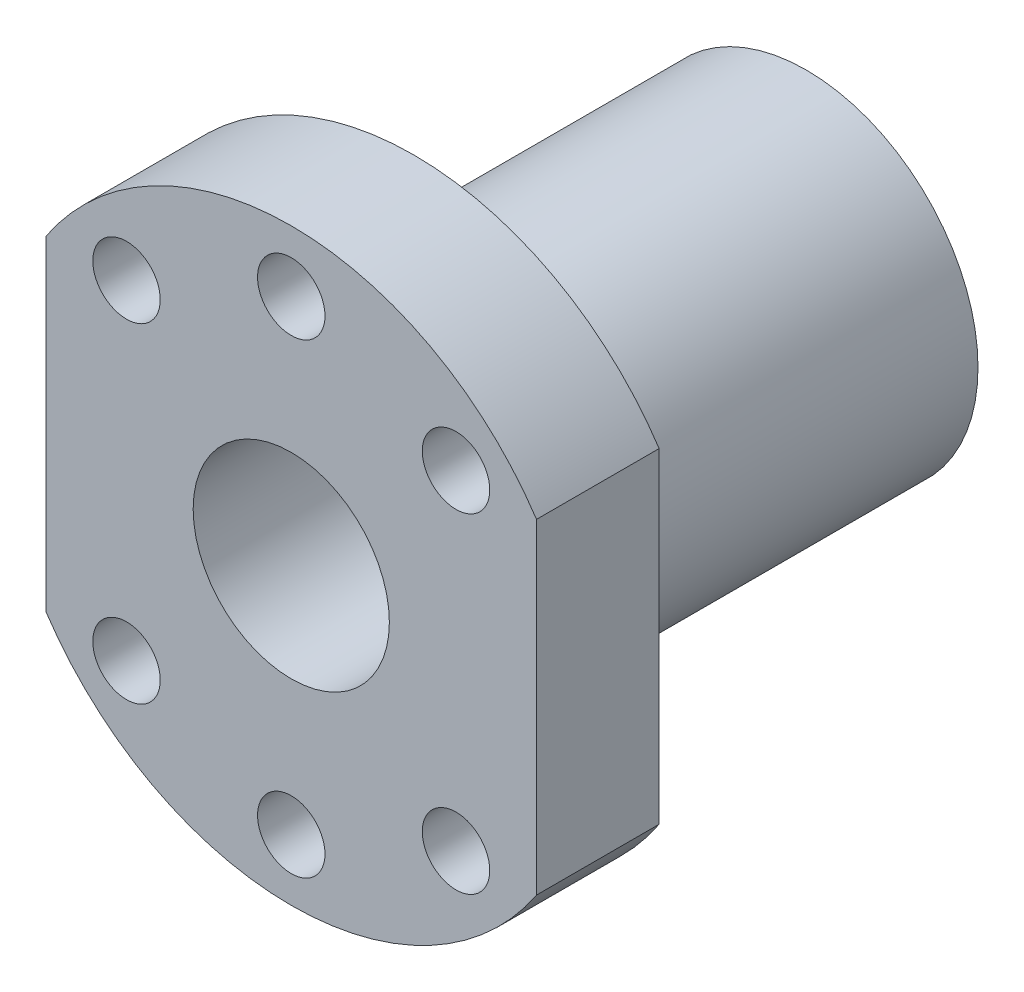
from build123d import *

# Parameters (mm, degrees)
EXTRUDE1_DEPTH = 10
SKETCH3_R      = 2.75
EXTRUDE2_DEPTH = 10


with BuildPart() as part:
    # Sketch1 → Revolve1 (revolve)
    with BuildSketch(Plane(origin=(0, 0, 0), x_dir=(0, 0, -1), z_dir=(1, 0, 0))):
        Polygon((-27.228213729, 44.343190328), (-17.228213729, 44.343190328), (-17.228213729, 34.343190328), (14.771786271, 34.343190328), (14.771786271, 28.343190328), (-27.228213729, 28.343190328), align=None)
    revolve(axis=Axis((0, 20.343190328, 76.875109204), (0, 0, -1)))

    # Sketch2 → Extrude1 (cut)
    with BuildSketch(Plane.XY.offset(27.228213729)):
        with BuildLine():
            Line((-20, 33.609689489), (-20, 7.076691166))
            ThreePointArc((-20, 7.076691166), (-24, 20.343190328), (-20, 33.609689489))
        make_face()
        with BuildLine():
            Line((20, 33.609689489), (20, 7.076691166))
            ThreePointArc((20, 7.076691166), (24, 20.343190328), (20, 33.609689489))
        make_face()
    extrude(amount=-EXTRUDE1_DEPTH, mode=Mode.SUBTRACT)

    # Sketch3 → Extrude2 (cut)
    with BuildSketch(Plane.XY.offset(27.228213729)):
        with Locations((13.435028843, 33.77821917)):
            Circle(SKETCH3_R)
        with Locations((0, 39.343190328)):
            Circle(SKETCH3_R)
        with Locations((-13.435028843, 33.77821917)):
            Circle(SKETCH3_R)
        with Locations((-13.435028843, 6.908161485)):
            Circle(SKETCH3_R)
        with Locations((0, 1.343190328)):
            Circle(SKETCH3_R)
        with Locations((13.435028843, 6.908161485)):
            Circle(SKETCH3_R)
    extrude(amount=-EXTRUDE2_DEPTH, mode=Mode.SUBTRACT)


solid = part.part
